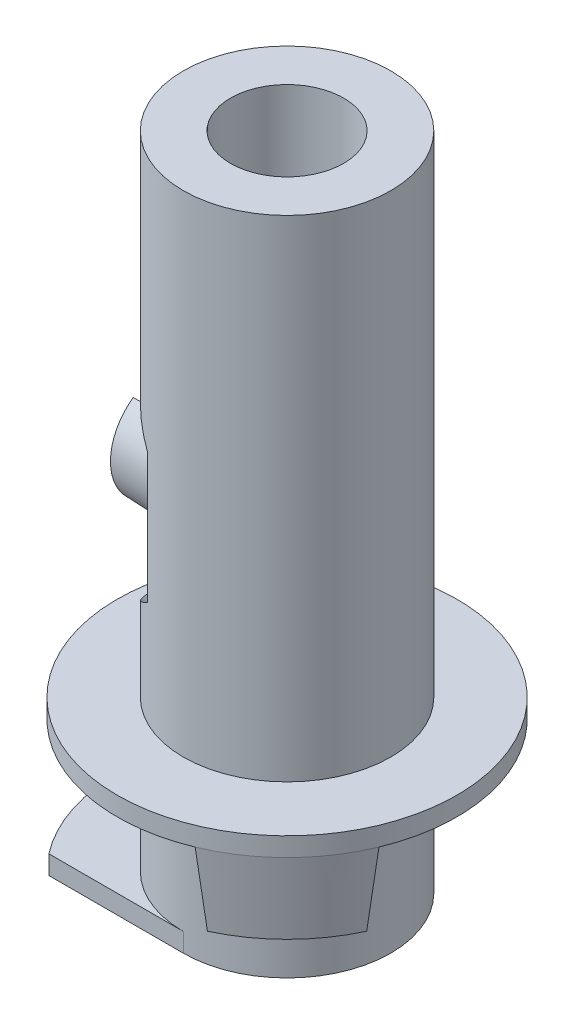
from build123d import *

# Parameters (mm, degrees)
SKETCH_1_R                = 4.5
EXTRUDE_1_DEPTH           = 17.5
SKETCH_2_W                = 1.75
SKETCH_2_H                = 13
SKETCH_3_W                = 1.75
SKETCH_3_H                = 3.5
CUT_EXTRUDE_1_DEPTH       = 0.5
EXTRUDE_2_DEPTH           = 2
EXTRUDE_2_DRAFT           = 5
SKETCH_7_R                = 3
CUT_EXTRUDE_2_DEPTH       = 1.5
SKETCH_8_R                = 1.5
EXTRUDE_3_DEPTH           = 2
EXTRUDE_3_TAPER           = 2
HOLE_WIZARD_1_D           = 2
HOLE_WIZARD_1_CBORE_D     = 3
HOLE_WIZARD_1_CBORE_DEPTH = 13
CUT_EXTRUDE_4_REACH       = 9.75
SKETCH_16_W               = 1.658312396
SKETCH_16_H               = 2.982539584


with BuildPart() as part:
    # 草图1 → 凸台-拉伸1 (new body)
    with BuildSketch(Plane(origin=(0, 0, 0), x_dir=(1, 0, 0), z_dir=(0, 1, 0))):
        Circle(SKETCH_1_R)
    extrude(amount=EXTRUDE_1_DEPTH)

    # 草图2 → 切除-旋转1 (revolve, cut)
    with BuildSketch(Plane.XY):
        with Locations((3.625, 11)):
            Rectangle(SKETCH_2_W, SKETCH_2_H)
    revolve(axis=Axis((0, 0, 0), (0, -1, 0)), mode=Mode.SUBTRACT)

    # 草图3 → 切除-旋转2 (revolve, cut)
    with BuildSketch(Plane.XY):
        with Locations((3.625, 2.25)):
            Rectangle(SKETCH_3_W, SKETCH_3_H)
    revolve(axis=Axis((0, 0, 0), (0, 1, 0)), mode=Mode.SUBTRACT)

    # 草图4 → 切除-拉伸1 (cut)
    with BuildSketch(Plane.XZ):
        with BuildLine():
            Line((0, 2.75), (-3.561951712, 2.75))
            ThreePointArc((-3.561951712, 2.75), (4.5, 0), (-3.561951712, -2.75))
            Line((-3.561951712, -2.75), (0, -2.75))
            ThreePointArc((0, -2.75), (2.75, 0), (0, 2.75))
        make_face()
    extrude(amount=-CUT_EXTRUDE_1_DEPTH, mode=Mode.SUBTRACT)


with BuildPart() as extrude_2_tool:
    # 草图6 → 凸台-拉伸2 (with draft: the straight prism first)
    with BuildSketch(Plane.XZ.offset(-4)):
        with BuildLine():
            ThreePointArc((1.339392013, 3.233578364), (2.474873734, 2.474873734), (3.233578364, 1.339392013))
            Line((3.233578364, 1.339392013), (4.157457896, 1.722075446))
            ThreePointArc((4.157457896, 1.722075446), (3.181980515, 3.181980515), (1.722075446, 4.157457896))
            Line((1.722075446, 4.157457896), (1.339392013, 3.233578364))
        make_face()
    extrude(amount=EXTRUDE_2_DEPTH)
    # 凸台-拉伸2: the draft: its side faces are tilted about the plane it starts from
    extrude_2_sides = [extrude_2_tool.faces().sort_by_distance(p)[0] for p in [
        (3.181980515, 3, 3.181980515),
        (1.530733729, 3, 3.69551813),
        (2.474873734, 3, 2.474873734),
        (3.69551813, 3, 1.530733729),
    ]]
    draft(extrude_2_sides, Plane.XZ.offset(-4), EXTRUDE_2_DRAFT)


with BuildPart() as part_1:
    add(part.part)

    # 凸台-拉伸2: add extrude_2_tool
    add(extrude_2_tool.part)

    # 草图7 → 切除-拉伸2 (cut)
    with BuildSketch(Plane(origin=(-2.75, 0, 0), x_dir=(0, 0, -1), z_dir=(1, 0, 0))):
        with Locations((0, 9)):
            Circle(SKETCH_7_R)
    extrude(amount=CUT_EXTRUDE_2_DEPTH, mode=Mode.SUBTRACT)

    # 草图8 → 凸台-拉伸3 (add)
    with BuildSketch(Plane.ZY.offset(1.25)):
        with Locations((0, 9)):
            Circle(SKETCH_8_R)
    extrude(amount=EXTRUDE_3_DEPTH, taper=EXTRUDE_3_TAPER)

    # 孔1 (through all)
    with Locations(Plane(origin=(0, 17.5, 0), x_dir=(1, 0, 0), z_dir=(0, 1, 0))):
        with Locations((0, 0)):
            CounterBoreHole(HOLE_WIZARD_1_D / 2, HOLE_WIZARD_1_CBORE_D / 2, HOLE_WIZARD_1_CBORE_DEPTH)

    # 草图16 → 切除-拉伸4 (cut, up to next)
    with BuildSketch(Plane.ZY.offset(3.25), mode=Mode.PRIVATE) as cut_extrude_4_sk1:
        with Locations((0, 9)):
            Rectangle(SKETCH_16_W, SKETCH_16_H)
    cut_extrude_4_tool1 = extrude(cut_extrude_4_sk1.sketch, amount=-CUT_EXTRUDE_4_REACH, mode=Mode.PRIVATE) & part_1.part
    add(cut_extrude_4_tool1.solids().sort_by_distance((-3.25, 9, 0))[0], mode=Mode.SUBTRACT)


solid = part_1.part
